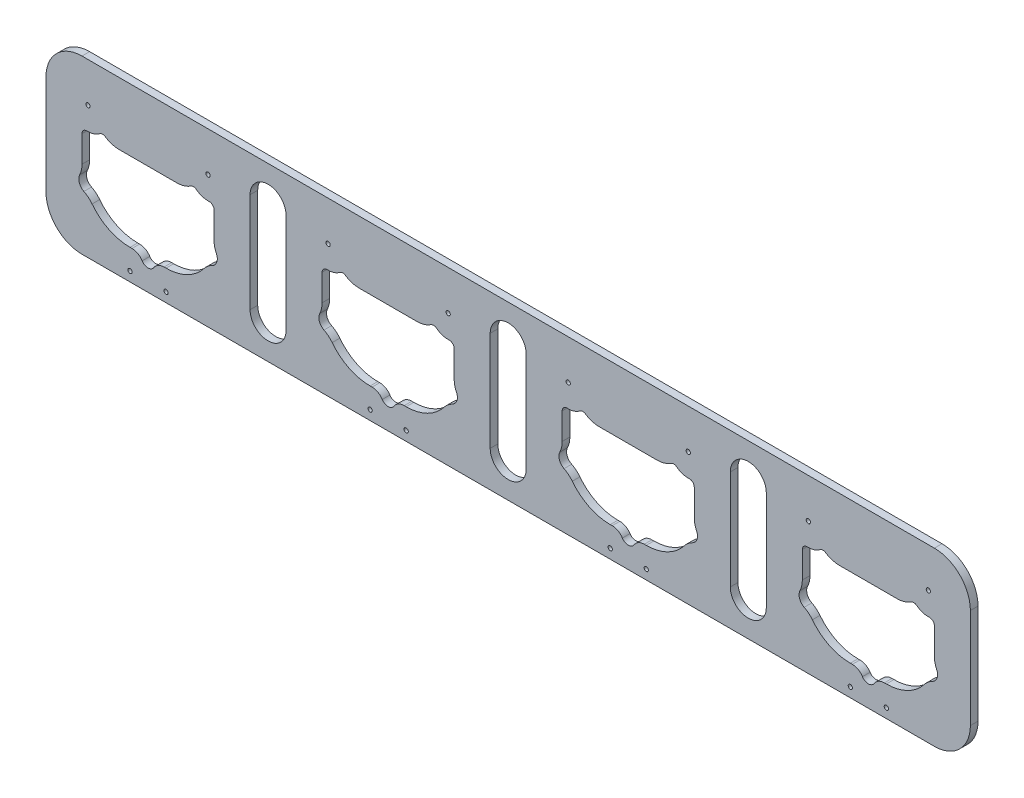
from build123d import *

# Parameters (mm, degrees)
SKETCH1_R           = 0.889
BOSS_EXTRUDE1_DEPTH = 3.175


with BuildPart() as part:
    # Sketch1 → Boss-Extrude1 (new body)
    with BuildSketch(Plane.XY):
        with BuildLine():
            Line((-20.79604899, 49.914446368), (334.20395101, 49.914446368))
            ThreePointArc((334.20395101, 49.914446368), (344.810552728, 45.521048086), (349.20395101, 34.914446368))
            Line((349.20395101, 34.914446368), (349.20395101, -6.585553632))
            ThreePointArc((349.20395101, -6.585553632), (344.810552728, -17.19215535), (334.20395101, -21.585553632))
            Line((334.20395101, -21.585553632), (-20.79604899, -21.585553632))
            ThreePointArc((-20.79604899, -21.585553632), (-31.402650708, -17.19215535), (-35.79604899, -6.585553632))
            Line((-35.79604899, -6.585553632), (-35.79604899, 34.914446368))
            ThreePointArc((-35.79604899, 34.914446368), (-31.402650708, 45.521048086), (-20.79604899, 49.914446368))
        make_face()
        with Locations((-18.29604899, 33.414446368)):
            Circle(SKETCH1_R, mode=Mode.SUBTRACT)
        with Locations((31.70395101, 33.414446368)):
            Circle(SKETCH1_R, mode=Mode.SUBTRACT)
        with Locations((14.20395101, -17.620299938)):
            Circle(SKETCH1_R, mode=Mode.SUBTRACT)
        with Locations((-0.79604899, -17.620299938)):
            Circle(SKETCH1_R, mode=Mode.SUBTRACT)
        with Locations((81.70395101, 33.414446368)):
            Circle(SKETCH1_R, mode=Mode.SUBTRACT)
        with Locations((131.70395101, 33.414446368)):
            Circle(SKETCH1_R, mode=Mode.SUBTRACT)
        with Locations((114.20395101, -17.620299938)):
            Circle(SKETCH1_R, mode=Mode.SUBTRACT)
        with Locations((99.20395101, -17.620299938)):
            Circle(SKETCH1_R, mode=Mode.SUBTRACT)
        with Locations((181.70395101, 33.414446368)):
            Circle(SKETCH1_R, mode=Mode.SUBTRACT)
        with Locations((231.70395101, 33.414446368)):
            Circle(SKETCH1_R, mode=Mode.SUBTRACT)
        with Locations((214.20395101, -17.620299938)):
            Circle(SKETCH1_R, mode=Mode.SUBTRACT)
        with Locations((199.20395101, -17.620299938)):
            Circle(SKETCH1_R, mode=Mode.SUBTRACT)
        with Locations((281.70395101, 33.414446368)):
            Circle(SKETCH1_R, mode=Mode.SUBTRACT)
        with Locations((331.70395101, 33.414446368)):
            Circle(SKETCH1_R, mode=Mode.SUBTRACT)
        with Locations((314.20395101, -17.620299938)):
            Circle(SKETCH1_R, mode=Mode.SUBTRACT)
        with Locations((299.20395101, -17.620299938)):
            Circle(SKETCH1_R, mode=Mode.SUBTRACT)
        with BuildLine():
            Line((-5.29604899, 23.914446368), (18.70395101, 23.914446368))
            ThreePointArc((18.70395101, 23.914446368), (21.730067428, 24.359963814), (24.499386196, 25.658709334))
            ThreePointArc((24.499386196, 25.658709334), (25.674712505, 25.989673792), (26.823413092, 25.575649193))
            ThreePointArc((26.823413092, 25.575649193), (29.316396291, 24.279030042), (32.10395101, 23.924452626))
            ThreePointArc((32.10395101, 23.924452626), (33.582355885, 23.376091865), (34.20395101, 21.92695419))
            Line((34.20395101, 21.92695419), (34.20395101, 10.914446368))
            ThreePointArc((34.20395101, 10.914446368), (34.20394869, 10.904812543), (34.203941729, 10.89517872))
            ThreePointArc((34.203941729, 10.89517872), (34.450091661, 8.680437329), (35.180585293, 6.575194286))
            ThreePointArc((35.180585293, 6.575194286), (35.348614524, 3.664847449), (33.430184326, 1.469858131))
            ThreePointArc((33.430184326, 1.469858131), (31.561617655, 0.255721477), (30.008315358, -1.342064864))
            ThreePointArc((30.008315358, -1.342064864), (23.003660533, -7.045651413), (14.20395101, -9.085553632))
            Line((14.20395101, -9.085553632), (13.381998704, -9.085553632))
            ThreePointArc((13.381998704, -9.085553632), (10.964321275, -9.708929837), (9.149492877, -11.423619293))
            ThreePointArc((9.149492877, -11.423619293), (6.70395101, -12.774553632), (4.258409143, -11.423619293))
            ThreePointArc((4.258409143, -11.423619293), (2.443580746, -9.708929837), (0.025903316, -9.085553632))
            Line((0.025903316, -9.085553632), (-0.79604899, -9.085553632))
            ThreePointArc((-0.79604899, -9.085553632), (-9.595758513, -7.045651413), (-16.600413337, -1.342064864))
            ThreePointArc((-16.600413337, -1.342064864), (-18.153715635, 0.255721477), (-20.022282306, 1.469858131))
            ThreePointArc((-20.022282306, 1.469858131), (-21.940712503, 3.664847449), (-21.772683273, 6.575194286))
            ThreePointArc((-21.772683273, 6.575194286), (-21.042189641, 8.680437329), (-20.796039709, 10.89517872))
            ThreePointArc((-20.796039709, 10.89517872), (-20.79604667, 10.904812543), (-20.79604899, 10.914446368))
            Line((-20.79604899, 10.914446368), (-20.79604899, 21.92695419))
            ThreePointArc((-20.79604899, 21.92695419), (-20.174453865, 23.376091865), (-18.69604899, 23.924452626))
            ThreePointArc((-18.69604899, 23.924452626), (-15.908494271, 24.279030042), (-13.415511072, 25.575649193))
            ThreePointArc((-13.415511072, 25.575649193), (-12.266810485, 25.989673792), (-11.091484176, 25.658709334))
            ThreePointArc((-11.091484176, 25.658709334), (-8.322165407, 24.359963814), (-5.29604899, 23.914446368))
        make_face(mode=Mode.SUBTRACT)
        with BuildLine():
            Line((94.70395101, 23.914446368), (118.70395101, 23.914446368))
            ThreePointArc((118.70395101, 23.914446368), (121.730067428, 24.359963814), (124.499386196, 25.658709334))
            ThreePointArc((124.499386196, 25.658709334), (125.674712505, 25.989673792), (126.823413092, 25.575649193))
            ThreePointArc((126.823413092, 25.575649193), (129.316396291, 24.279030042), (132.10395101, 23.924452626))
            ThreePointArc((132.10395101, 23.924452626), (133.582355885, 23.376091865), (134.20395101, 21.92695419))
            Line((134.20395101, 21.92695419), (134.20395101, 10.914446368))
            ThreePointArc((134.20395101, 10.914446368), (134.20394869, 10.904812543), (134.203941729, 10.89517872))
            ThreePointArc((134.203941729, 10.89517872), (134.450091661, 8.680437329), (135.180585293, 6.575194286))
            ThreePointArc((135.180585293, 6.575194286), (135.348614524, 3.664847449), (133.430184326, 1.469858131))
            ThreePointArc((133.430184326, 1.469858131), (131.561617655, 0.255721477), (130.008315358, -1.342064864))
            ThreePointArc((130.008315358, -1.342064864), (123.003660533, -7.045651413), (114.20395101, -9.085553632))
            Line((114.20395101, -9.085553632), (113.381998704, -9.085553632))
            ThreePointArc((113.381998704, -9.085553632), (110.964321275, -9.708929837), (109.149492877, -11.423619293))
            ThreePointArc((109.149492877, -11.423619293), (106.70395101, -12.774553632), (104.258409143, -11.423619293))
            ThreePointArc((104.258409143, -11.423619293), (102.443580746, -9.708929837), (100.025903316, -9.085553632))
            Line((100.025903316, -9.085553632), (99.20395101, -9.085553632))
            ThreePointArc((99.20395101, -9.085553632), (90.404241487, -7.045651413), (83.399586663, -1.342064864))
            ThreePointArc((83.399586663, -1.342064864), (81.846284365, 0.255721477), (79.977717694, 1.469858131))
            ThreePointArc((79.977717694, 1.469858131), (78.059287497, 3.664847449), (78.227316727, 6.575194286))
            ThreePointArc((78.227316727, 6.575194286), (78.957810359, 8.680437329), (79.203960291, 10.89517872))
            ThreePointArc((79.203960291, 10.89517872), (79.20395333, 10.904812543), (79.20395101, 10.914446368))
            Line((79.20395101, 10.914446368), (79.20395101, 21.92695419))
            ThreePointArc((79.20395101, 21.92695419), (79.825546135, 23.376091865), (81.30395101, 23.924452626))
            ThreePointArc((81.30395101, 23.924452626), (84.091505729, 24.279030042), (86.584488928, 25.575649193))
            ThreePointArc((86.584488928, 25.575649193), (87.733189515, 25.989673792), (88.908515824, 25.658709334))
            ThreePointArc((88.908515824, 25.658709334), (91.677834593, 24.359963814), (94.70395101, 23.914446368))
        make_face(mode=Mode.SUBTRACT)
        with BuildLine():
            Line((149.20395101, 34.914446368), (149.20395101, -6.585553632))
            ThreePointArc((149.20395101, -6.585553632), (156.70395101, -14.085553632), (164.20395101, -6.585553632))
            Line((164.20395101, -6.585553632), (164.20395101, 34.914446368))
            ThreePointArc((164.20395101, 34.914446368), (156.70395101, 42.414446368), (149.20395101, 34.914446368))
        make_face(mode=Mode.SUBTRACT)
        with BuildLine():
            Line((194.70395101, 23.914446368), (218.70395101, 23.914446368))
            ThreePointArc((218.70395101, 23.914446368), (221.730067428, 24.359963814), (224.499386196, 25.658709334))
            ThreePointArc((224.499386196, 25.658709334), (225.674712505, 25.989673792), (226.823413092, 25.575649193))
            ThreePointArc((226.823413092, 25.575649193), (229.316396291, 24.279030042), (232.10395101, 23.924452626))
            ThreePointArc((232.10395101, 23.924452626), (233.582355885, 23.376091865), (234.20395101, 21.92695419))
            Line((234.20395101, 21.92695419), (234.20395101, 10.914446368))
            ThreePointArc((234.20395101, 10.914446368), (234.20394869, 10.904812543), (234.203941729, 10.89517872))
            ThreePointArc((234.203941729, 10.89517872), (234.450091661, 8.680437329), (235.180585293, 6.575194286))
            ThreePointArc((235.180585293, 6.575194286), (235.348614524, 3.664847449), (233.430184326, 1.469858131))
            ThreePointArc((233.430184326, 1.469858131), (231.561617655, 0.255721477), (230.008315358, -1.342064864))
            ThreePointArc((230.008315358, -1.342064864), (223.003660533, -7.045651413), (214.20395101, -9.085553632))
            Line((214.20395101, -9.085553632), (213.381998704, -9.085553632))
            ThreePointArc((213.381998704, -9.085553632), (210.964321275, -9.708929837), (209.149492877, -11.423619293))
            ThreePointArc((209.149492877, -11.423619293), (206.70395101, -12.774553632), (204.258409143, -11.423619293))
            ThreePointArc((204.258409143, -11.423619293), (202.443580746, -9.708929837), (200.025903316, -9.085553632))
            Line((200.025903316, -9.085553632), (199.20395101, -9.085553632))
            ThreePointArc((199.20395101, -9.085553632), (190.404241487, -7.045651413), (183.399586663, -1.342064864))
            ThreePointArc((183.399586663, -1.342064864), (181.846284365, 0.255721477), (179.977717694, 1.469858131))
            ThreePointArc((179.977717694, 1.469858131), (178.059287497, 3.664847449), (178.227316727, 6.575194286))
            ThreePointArc((178.227316727, 6.575194286), (178.957810359, 8.680437329), (179.203960291, 10.89517872))
            ThreePointArc((179.203960291, 10.89517872), (179.20395333, 10.904812543), (179.20395101, 10.914446368))
            Line((179.20395101, 10.914446368), (179.20395101, 21.92695419))
            ThreePointArc((179.20395101, 21.92695419), (179.825546135, 23.376091865), (181.30395101, 23.924452626))
            ThreePointArc((181.30395101, 23.924452626), (184.091505729, 24.279030042), (186.584488928, 25.575649193))
            ThreePointArc((186.584488928, 25.575649193), (187.733189515, 25.989673792), (188.908515824, 25.658709334))
            ThreePointArc((188.908515824, 25.658709334), (191.677834593, 24.359963814), (194.70395101, 23.914446368))
        make_face(mode=Mode.SUBTRACT)
        with BuildLine():
            Line((249.20395101, 34.914446368), (249.20395101, -6.585553632))
            ThreePointArc((249.20395101, -6.585553632), (256.70395101, -14.085553632), (264.20395101, -6.585553632))
            Line((264.20395101, -6.585553632), (264.20395101, 34.914446368))
            ThreePointArc((264.20395101, 34.914446368), (256.70395101, 42.414446368), (249.20395101, 34.914446368))
        make_face(mode=Mode.SUBTRACT)
        with BuildLine():
            Line((294.70395101, 23.914446368), (318.70395101, 23.914446368))
            ThreePointArc((318.70395101, 23.914446368), (321.730067428, 24.359963814), (324.499386196, 25.658709334))
            ThreePointArc((324.499386196, 25.658709334), (325.674712505, 25.989673792), (326.823413092, 25.575649193))
            ThreePointArc((326.823413092, 25.575649193), (329.316396291, 24.279030042), (332.10395101, 23.924452626))
            ThreePointArc((332.10395101, 23.924452626), (333.582355885, 23.376091865), (334.20395101, 21.92695419))
            Line((334.20395101, 21.92695419), (334.20395101, 10.914446368))
            ThreePointArc((334.20395101, 10.914446368), (334.20394869, 10.904812543), (334.203941729, 10.89517872))
            ThreePointArc((334.203941729, 10.89517872), (334.450091661, 8.680437329), (335.180585293, 6.575194286))
            ThreePointArc((335.180585293, 6.575194286), (335.348614524, 3.664847449), (333.430184326, 1.469858131))
            ThreePointArc((333.430184326, 1.469858131), (331.561617655, 0.255721477), (330.008315358, -1.342064864))
            ThreePointArc((330.008315358, -1.342064864), (323.003660533, -7.045651413), (314.20395101, -9.085553632))
            Line((314.20395101, -9.085553632), (313.381998704, -9.085553632))
            ThreePointArc((313.381998704, -9.085553632), (310.964321275, -9.708929837), (309.149492877, -11.423619293))
            ThreePointArc((309.149492877, -11.423619293), (306.70395101, -12.774553632), (304.258409143, -11.423619293))
            ThreePointArc((304.258409143, -11.423619293), (302.443580746, -9.708929837), (300.025903316, -9.085553632))
            Line((300.025903316, -9.085553632), (299.20395101, -9.085553632))
            ThreePointArc((299.20395101, -9.085553632), (290.404241487, -7.045651413), (283.399586663, -1.342064864))
            ThreePointArc((283.399586663, -1.342064864), (281.846284365, 0.255721477), (279.977717694, 1.469858131))
            ThreePointArc((279.977717694, 1.469858131), (278.059287497, 3.664847449), (278.227316727, 6.575194286))
            ThreePointArc((278.227316727, 6.575194286), (278.957810359, 8.680437329), (279.203960291, 10.89517872))
            ThreePointArc((279.203960291, 10.89517872), (279.20395333, 10.904812543), (279.20395101, 10.914446368))
            Line((279.20395101, 10.914446368), (279.20395101, 21.92695419))
            ThreePointArc((279.20395101, 21.92695419), (279.825546135, 23.376091865), (281.30395101, 23.924452626))
            ThreePointArc((281.30395101, 23.924452626), (284.091505729, 24.279030042), (286.584488928, 25.575649193))
            ThreePointArc((286.584488928, 25.575649193), (287.733189515, 25.989673792), (288.908515824, 25.658709334))
            ThreePointArc((288.908515824, 25.658709334), (291.677834593, 24.359963814), (294.70395101, 23.914446368))
        make_face(mode=Mode.SUBTRACT)
        with BuildLine():
            Line((49.20395101, 34.914446368), (49.20395101, -6.585553632))
            ThreePointArc((49.20395101, -6.585553632), (56.70395101, -14.085553632), (64.20395101, -6.585553632))
            Line((64.20395101, -6.585553632), (64.20395101, 34.914446368))
            ThreePointArc((64.20395101, 34.914446368), (56.70395101, 42.414446368), (49.20395101, 34.914446368))
        make_face(mode=Mode.SUBTRACT)
    extrude(amount=BOSS_EXTRUDE1_DEPTH)


solid = part.part
